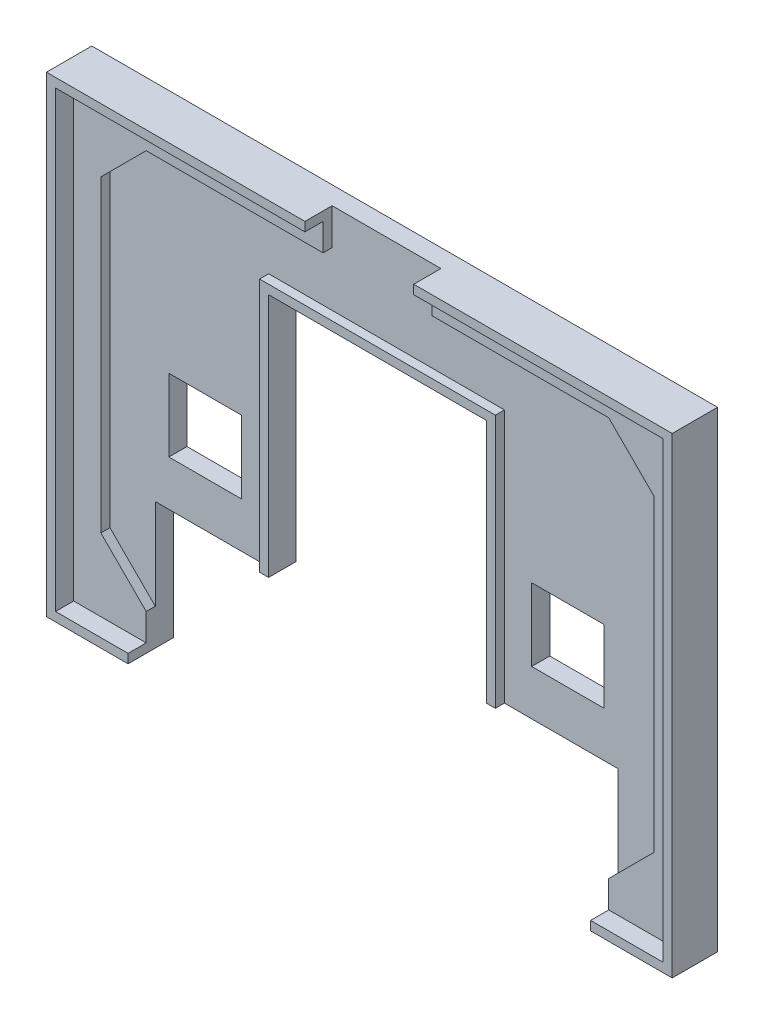
from build123d import *

# Parameters (mm, degrees)
SKICA1_W                    = 67
SKICA1_H                    = 50
P_IDAT_VYSUNUT_M1_DEPTH     = 3
ODEBRAT_VYSUNUT_M1_DEPTH    = 1
SKICA3_W                    = 8
SKICA3_H                    = 8
ODEBRAT_VYSUNUT_M2_DEPTH    = 4
VYSUNOUT_TENKOST_NN_1_DEPTH = 1
VYSUNOUT_TENKOST_NN_2_DEPTH = 5
SKICA6_W                    = 12
SKICA6_H                    = 4
ODEBRAT_VYSUNUT_M3_DEPTH    = 4
ODEBRAT_VYSUNUT_M4_DEPTH    = 1
P_IDAT_START                = -1
SKICA9_W                    = 2
SKICA9_H                    = 2
P_IDAT_VYSUNUT_M2_DEPTH     = 1
SKICA11_W                   = 1
SKICA11_H                   = 1
P_IDAT_VYSUNUT_M3_DEPTH     = 1
ODEBRAT_VYSUNUT_M5_DEPTH    = 1
SKICA13_W                   = 1.599771115
SKICA13_H                   = 1.6
SKICA13_W_2                 = 1.6
SKICA13_H_2                 = 2.4
P_IDAT_VYSUNUT_M4_DEPTH     = 1


with BuildPart() as part:
    # Skica1 → Přidat vysunutím1 (new body)
    with BuildSketch(Plane.XY):
        Rectangle(SKICA1_W, SKICA1_H)
    extrude(amount=P_IDAT_VYSUNUT_M1_DEPTH)

    # Skica2 → Odebrat vysunutím1 (cut)
    with BuildSketch(Plane.XY.offset(3)):
        Polygon((-25.5, -22), (-30.5, -17), (-30.5, 17), (-25.5, 22), (25.5, 22), (30.5, 17), (30.5, -17), (25.5, -22), align=None)
    extrude(amount=-ODEBRAT_VYSUNUT_M1_DEPTH, mode=Mode.SUBTRACT)

    # Skica3 → Odebrat vysunutím2 (cut, through all)
    with BuildSketch(Plane(origin=(0, 0, 0), x_dir=(-1, 0, 0), z_dir=(0, 0, -1))):
        with Locations((20, -3)):
            Rectangle(SKICA3_W, SKICA3_H)
        with Locations((-20, -3)):
            Rectangle(SKICA3_W, SKICA3_H)
        Polygon((25.5, -25), (-25.5, -25), (-25.5, -12), (-12, -12), (-12, 15), (12, 15), (12, -12), (25.5, -12), align=None)
    extrude(amount=-ODEBRAT_VYSUNUT_M2_DEPTH, mode=Mode.SUBTRACT)

    # Skica4 → Vysunout tenkostěnný1 (add)
    with BuildSketch(Plane.XY.offset(2)):
        Polygon((-12, -12), (-12, 15), (12, 15), (12, -12), (13, -12), (13, 16), (-13, 16), (-13, -12), align=None)
    extrude(amount=VYSUNOUT_TENKOST_NN_1_DEPTH)

    # Skica5 → Vysunout tenkostěnný2 (add)
    with BuildSketch(Plane(origin=(0, 0, 0), x_dir=(-1, 0, 0), z_dir=(0, 0, -1))):
        Polygon((-25.5, -25), (-33.5, -25), (-33.5, 25), (33.5, 25), (33.5, -25), (25.5, -25), (25.5, -26), (34.5, -26), (34.5, 26), (-34.5, 26), (-34.5, -26), (-25.5, -26), align=None)
    extrude(amount=-VYSUNOUT_TENKOST_NN_2_DEPTH)

    # Skica6 → Odebrat vysunutím3 (cut, through all)
    with BuildSketch(Plane.XY.offset(2)):
        with Locations((0, 24)):
            Rectangle(SKICA6_W, SKICA6_H)
    extrude(amount=ODEBRAT_VYSUNUT_M3_DEPTH, mode=Mode.SUBTRACT)

    # Skica8 → Odebrat vysunutím4 (cut)
    with BuildSketch(Plane(origin=(0, 0, 0), x_dir=(-1, 0, 0), z_dir=(0, 0, -1))):
        Polygon((-28.752217352, 22), (-27.75, 22), (-27.75, 21), (-26.75, 21), (-26.75, 20), (-25.75, 20), (-25.75, 19), (-20.75, 19), (-20.75, 20), (-19.75, 20), (-19.75, 21), (-18.75, 21), (-18.75, 22), (-17.75, 22), (-17.75, 21), (-16.75, 21), (-16.75, 19), (-15.75, 19), (-15.75, 15), (-14.75, 15), (-14.75, 11), (-15.75, 11), (-15.75, 10), (-16.75, 10), (-16.75, 9), (-17.75, 9), (-17.75, 8), (-18.75, 8), (-18.75, 7), (-27.752217352, 7), (-27.752217352, 8), (-28.752217352, 8), (-28.752217352, 9), (-29.752217352, 9), (-29.752217352, 10), (-30.752217352, 10), (-30.752217352, 11), (-31.752217352, 11), (-31.752217352, 15), (-30.752217352, 15), (-30.752217352, 19), (-29.752217352, 19), (-29.752217352, 21), (-28.752217352, 21), align=None)
        Polygon((25.75, 19), (20.75, 19), (20.75, 20), (19.75, 20), (19.75, 21), (18.75, 21), (18.75, 22), (17.75, 22), (17.75, 21), (16.75, 21), (16.75, 19), (15.75, 19), (15.75, 15), (14.75, 15), (14.75, 11), (15.75, 11), (15.75, 10), (16.75, 10), (16.75, 9), (17.75, 9), (17.75, 8), (18.75, 8), (18.75, 7), (27.752217352, 7), (27.752217352, 8), (28.752217352, 8), (28.752217352, 9), (29.752217352, 9), (29.752217352, 10), (30.752217352, 10), (30.752217352, 11), (31.752217352, 11), (31.752217352, 15), (30.752217352, 15), (30.752217352, 19), (29.752217352, 19), (29.752217352, 21), (28.752217352, 21), (28.752217352, 22), (27.75, 22), (27.75, 21), (26.75, 21), (26.75, 20), (25.75, 20), align=None)
    extrude(amount=-ODEBRAT_VYSUNUT_M4_DEPTH, mode=Mode.SUBTRACT)

    # Skica9 → Přidat vysunutím2 (add)
    with BuildSketch(Plane(origin=(0, 0, 0), x_dir=(-1, 0, 0), z_dir=(0, 0, -1)).offset(P_IDAT_START)):
        with Locations((-26.75, 13)):
            Rectangle(SKICA9_W, SKICA9_H)
        Polygon((-21.75, 10), (-21.75, 9), (-24.75, 9), (-24.75, 10), (-23.75, 10), (-23.75, 12), (-22.75, 12), (-22.75, 10), align=None)
        with Locations((-19.75, 13)):
            Rectangle(SKICA9_W, SKICA9_H)
        Polygon((24.75, 10), (23.75, 10), (23.75, 12), (22.75, 12), (22.75, 10), (21.75, 10), (21.75, 9), (24.75, 9), align=None)
        with Locations((19.75, 13)):
            Rectangle(SKICA9_W, SKICA9_H)
        with Locations((26.75, 13)):
            Rectangle(SKICA9_W, SKICA9_H)
    extrude(amount=P_IDAT_VYSUNUT_M2_DEPTH)

    # Skica11 → Přidat vysunutím3 (add)
    with BuildSketch(Plane(origin=(0, 0, 0), x_dir=(-1, 0, 0), z_dir=(0, 0, -1)).offset(P_IDAT_START)):
        with Locations((-21.24999, 10.50001)):
            Rectangle(SKICA11_W, SKICA11_H)
        with Locations((-25.252227352, 10.50001)):
            Rectangle(SKICA11_W, SKICA11_H)
        with Locations((21.24999, 10.50001)):
            Rectangle(SKICA11_W, SKICA11_H)
        with Locations((25.252227352, 10.50001)):
            Rectangle(SKICA11_W, SKICA11_H)
    extrude(amount=P_IDAT_VYSUNUT_M3_DEPTH)

    # Skica12 → Odebrat vysunutím5 (cut)
    with BuildSketch(Plane(origin=(0, 0, 0), x_dir=(-1, 0, 0), z_dir=(0, 0, -1))):
        Polygon((-11.1, 23.3), (-9.5, 23.3), (-9.5, 20.9), (-7.9, 20.9), (-7.9, 23.3), (-6.3, 23.3), (-6.3, 17.7), (-7.9, 17.7), (-7.9, 20.1), (-9.5, 20.1), (-9.5, 17.7), (-11.1, 17.7), align=None)
        Polygon((-1.300228885, 23.3), (-4.5, 23.3), (-4.5, 22.5), (-5.3, 22.5), (-5.3, 17.7), (-3.7, 17.7), (-3.7, 20.1), (-2.100228885, 20.1), (-2.100228885, 17.7), (-0.500228885, 17.7), (-0.500228885, 22.5), (-1.300228885, 22.5), align=None)
        Polygon((0.499771115, 23.3), (5.299771115, 23.3), (5.299771115, 22.1), (2.099771115, 22.1), (2.099771115, 20.9), (4.499771115, 20.9), (4.499771115, 19.7), (2.099771115, 19.7), (2.099771115, 17.7), (0.499771115, 17.7), align=None)
        Polygon((7.099771115, 23.3), (10.299771115, 23.3), (10.299771115, 22.5), (11.099771115, 22.5), (11.099771115, 18.5), (10.299771115, 18.5), (10.299771115, 17.7), (7.099771115, 17.7), (7.099771115, 18.5), (6.299771115, 18.5), (6.299771115, 22.5), (7.099771115, 22.5), align=None)
    extrude(amount=-ODEBRAT_VYSUNUT_M5_DEPTH, mode=Mode.SUBTRACT)

    # Skica13 → Přidat vysunutím4 (add)
    with BuildSketch(Plane(origin=(0, 0, 0), x_dir=(-1, 0, 0), z_dir=(0, 0, -1)).offset(P_IDAT_START)):
        with Locations((-2.900114443, 21.7)):
            Rectangle(SKICA13_W, SKICA13_H)
        with Locations((8.699771115, 20.5)):
            Rectangle(SKICA13_W_2, SKICA13_H_2)
    extrude(amount=P_IDAT_VYSUNUT_M4_DEPTH)


solid = part.part
